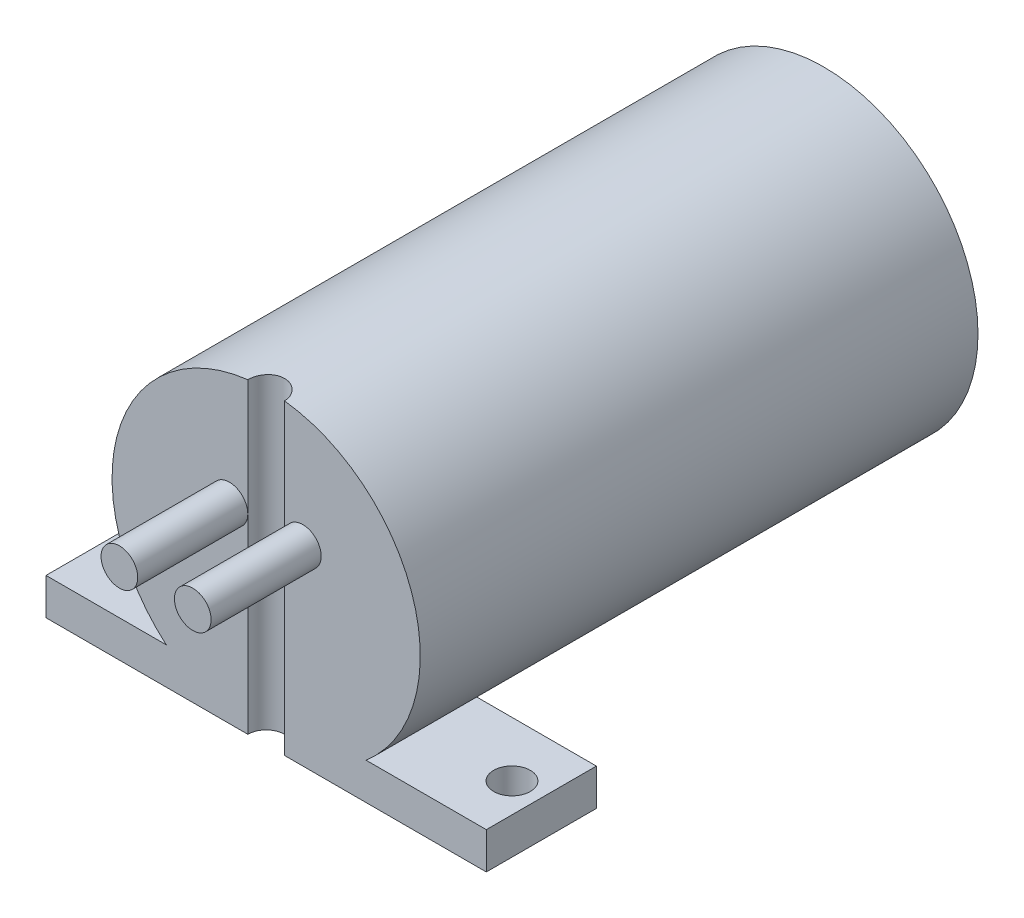
from build123d import *

# Parameters (mm, degrees)
SKETCH1_R                    = 13.335
BOSS_EXTRUDE1_DEPTH          = 48.26
SKETCH2_W                    = 38.1
SKETCH2_H                    = 9.525
BOSS_EXTRUDE2_DEPTH          = 3.175
F_1_8_0_125_DIAMETER_HOLE1_D = 3.175
SKETCH5_R                    = 1.5875
BOSS_EXTRUDE3_DEPTH          = 9.525


with BuildPart() as part:
    # Sketch1 → Boss-Extrude1 (new body)
    with BuildSketch(Plane.XY):
        Circle(SKETCH1_R)
    extrude(amount=BOSS_EXTRUDE1_DEPTH)

    # Sketch2 → Boss-Extrude2 (add)
    with BuildSketch(Plane(origin=(0, -13.335, 0), x_dir=(-1, 0, 0), z_dir=(0, -1, 0))):
        with Locations((0, -43.4975)):
            Rectangle(SKETCH2_W, SKETCH2_H)
    extrude(amount=-BOSS_EXTRUDE2_DEPTH)

    # 1/8 (0.125) Diameter Hole1 (through all)
    with Locations(Plane(origin=(0, -13.335, 0), x_dir=(-1, 0, 0), z_dir=(0, -1, 0))):
        with Locations((-16.51, -43.4975), (16.51, -43.4975), (0, -48.26)):
            Hole(F_1_8_0_125_DIAMETER_HOLE1_D / 2)

    # Sketch5 → Boss-Extrude3 (add)
    with BuildSketch(Plane.XY.offset(48.26)):
        with Locations((-3.175, 3.175)):
            Circle(SKETCH5_R)
        with Locations((3.175, 3.175)):
            Circle(SKETCH5_R)
    extrude(amount=BOSS_EXTRUDE3_DEPTH)


solid = part.part
